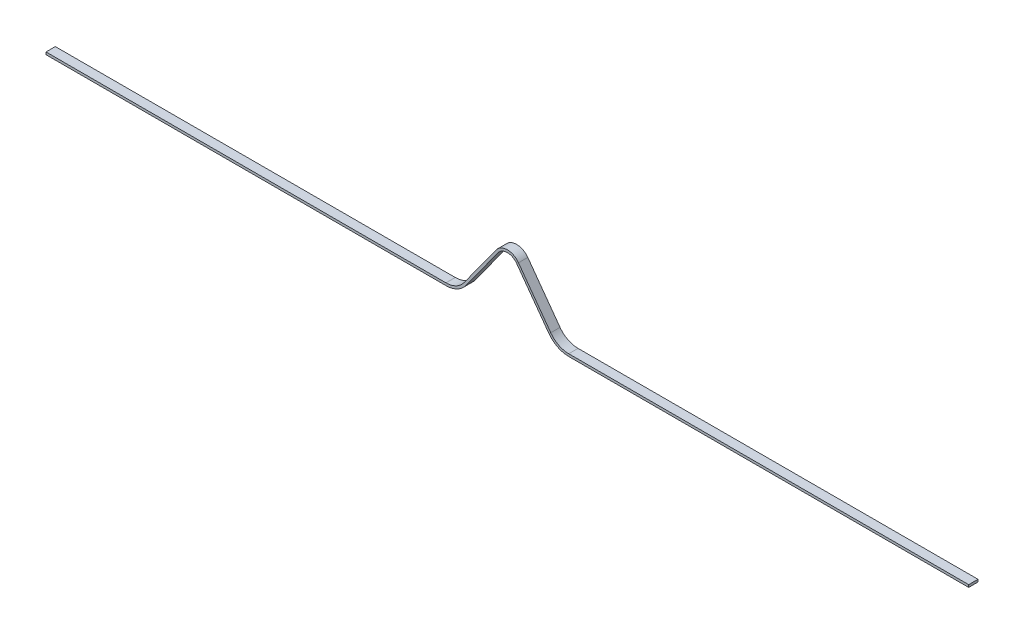
from build123d import *

# Parameters (mm, degrees)
EXTRUDE_THIN1_DEPTH = 2.5


with BuildPart() as part:
    # Sketch1 → Extrude-Thin1 (new body, symmetric)
    with BuildSketch(Plane.XY):
        with BuildLine():
            Line((-248, -24.5), (-33, -24.5))
            ThreePointArc((-33, -24.5), (-27.56956187, -23.194850479), (-23.325321853, -19.564492338))
            Line((-23.325321853, -19.564492338), (-5.991014082, 4.343702368))
            ThreePointArc((-5.991014082, 4.343702368), (0, 7.4), (5.991014082, 4.343702368))
            Line((5.991014082, 4.343702368), (23.325321853, -19.564492338))
            ThreePointArc((23.325321853, -19.564492338), (27.56956187, -23.194850479), (33, -24.5))
            Line((33, -24.5), (248, -24.5))
            Line((248, -24.5), (248, -25.8))
            Line((248, -25.8), (33, -25.8))
            ThreePointArc((33, -25.8), (26.978802911, -24.352867686), (22.272846406, -20.327575186))
            Line((22.272846406, -20.327575186), (4.938538636, 3.58061952))
            ThreePointArc((4.938538636, 3.58061952), (0, 6.1), (-4.938538636, 3.58061952))
            Line((-4.938538636, 3.58061952), (-22.272846406, -20.327575186))
            ThreePointArc((-22.272846406, -20.327575186), (-26.978802911, -24.352867686), (-33, -25.8))
            Line((-33, -25.8), (-248, -25.8))
            Line((-248, -25.8), (-248, -24.5))
        make_face()
    extrude(amount=EXTRUDE_THIN1_DEPTH, both=True)


solid = part.part
